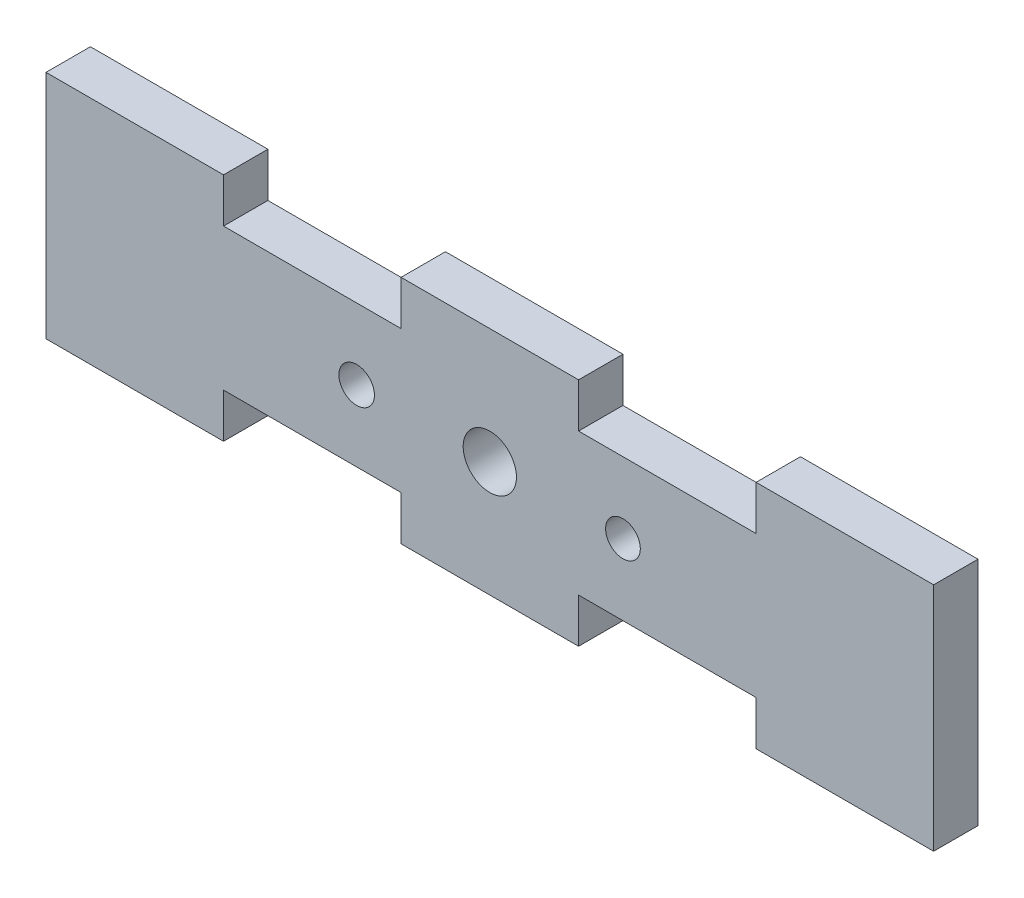
from build123d import *

# Parameters (mm, degrees)
CROQUIS1_R              = 1.5
CROQUIS1_R_2            = 0.977820283
CROQUIS1_R_3            = 1
SALIENTE_EXTRUIR1_DEPTH = 2.5


with BuildPart() as part:
    # Croquis1 → Saliente-Extruir1 (new body)
    with BuildSketch(Plane.XY):
        Polygon((-25, 6.5), (-15, 6.5), (-15, 4), (-5, 4), (-5, 6.5), (5, 6.5), (5, 4), (15, 4), (15, 6.5), (25, 6.5), (25, -6.5), (15, -6.5), (15, -4), (5, -4), (5, -6.5), (-5, -6.5), (-5, -4), (-15, -4), (-15, -6.5), (-25, -6.5), align=None)
        Circle(CROQUIS1_R, mode=Mode.SUBTRACT)
        with Locations((7.5, 0)):
            Circle(CROQUIS1_R_2, mode=Mode.SUBTRACT)
        with Locations((-7.5, 0)):
            Circle(CROQUIS1_R_3, mode=Mode.SUBTRACT)
    extrude(amount=SALIENTE_EXTRUIR1_DEPTH)


solid = part.part
